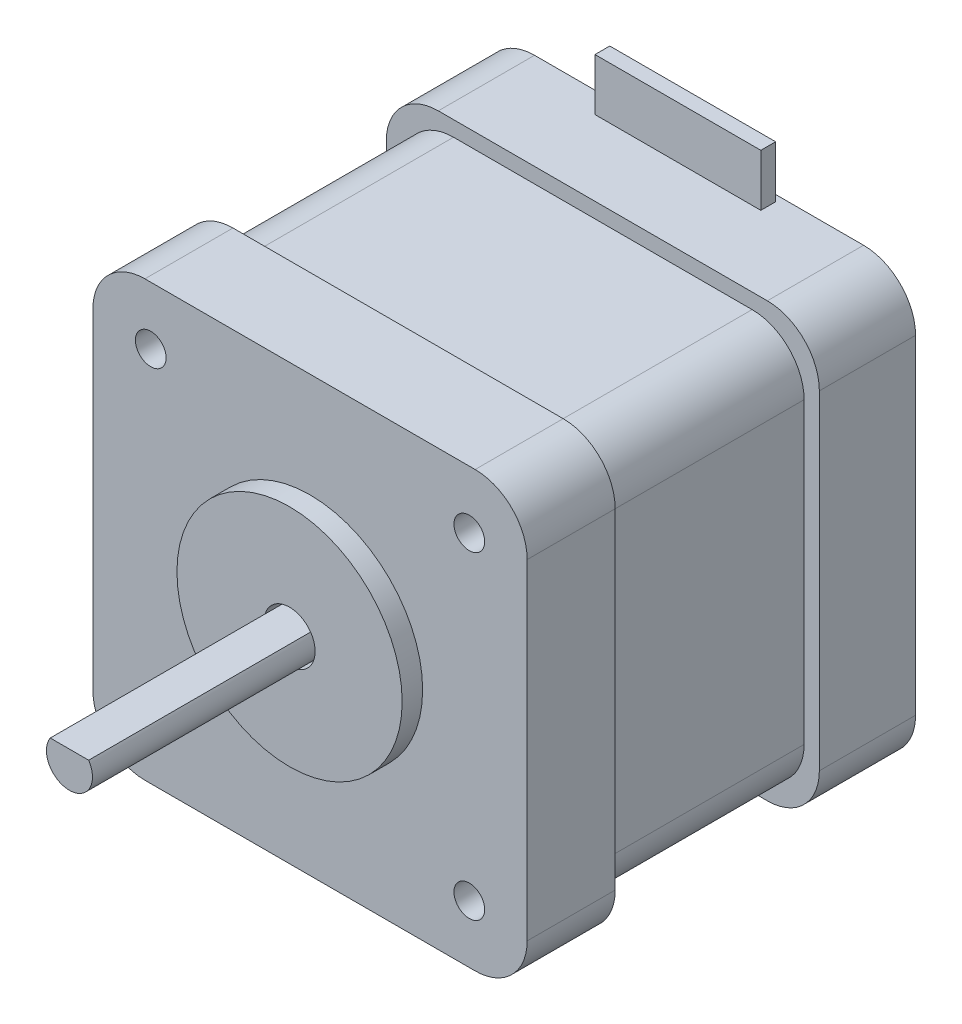
from build123d import *

# Parameters (mm, degrees)
BOSS_EXTRUDE1_DEPTH = 9.4
BOSS_EXTRUDE2_DEPTH = 20
BOSS_EXTRUDE4_DEPTH = 8.6
SKETCH5_R           = 11
BOSS_EXTRUDE5_DEPTH = 2
SKETCH6_R           = 2.5
CUT_EXTRUDE1_DEPTH  = 2
BOSS_EXTRUDE6_DEPTH = 23.5
SKETCH8_W           = 16.2
SKETCH8_H           = 1.444611315
BOSS_EXTRUDE7_DEPTH = 5.08
SKETCH9_R           = 1.5
CUT_EXTRUDE2_DEPTH  = 4.5


with BuildPart() as part:
    # Sketch1 → Boss-Extrude1 (new body)
    with BuildSketch(Plane.XY):
        with BuildLine():
            Line((-16.07, -21.15), (16.07, -21.15))
            ThreePointArc((16.07, -21.15), (19.662102448, -19.662102448), (21.15, -16.07))
            Line((21.15, -16.07), (21.15, 16.07))
            ThreePointArc((21.15, 16.07), (19.662102448, 19.662102448), (16.07, 21.15))
            Line((16.07, 21.15), (-16.07, 21.15))
            ThreePointArc((-16.07, 21.15), (-19.662102448, 19.662102448), (-21.15, 16.07))
            Line((-21.15, 16.07), (-21.15, -16.07))
            ThreePointArc((-21.15, -16.07), (-19.662102448, -19.662102448), (-16.07, -21.15))
        make_face()
    extrude(amount=BOSS_EXTRUDE1_DEPTH)

    # Sketch2 → Boss-Extrude2 (add)
    with BuildSketch(Plane.XY.offset(9.4)):
        with BuildLine():
            Line((-14.582102448, -19.662102448), (14.582102448, -19.662102448))
            ThreePointArc((14.582102448, -19.662102448), (18.174204897, -18.174204897), (19.662102448, -14.582102448))
            Line((19.662102448, -14.582102448), (19.662102448, 14.582102448))
            ThreePointArc((19.662102448, 14.582102448), (18.174204897, 18.174204897), (14.582102448, 19.662102448))
            Line((14.582102448, 19.662102448), (-14.582102448, 19.662102448))
            ThreePointArc((-14.582102448, 19.662102448), (-18.174204897, 18.174204897), (-19.662102448, 14.582102448))
            Line((-19.662102448, 14.582102448), (-19.662102448, -14.582102448))
            ThreePointArc((-19.662102448, -14.582102448), (-18.174204897, -18.174204897), (-14.582102448, -19.662102448))
        make_face()
    extrude(amount=BOSS_EXTRUDE2_DEPTH)

    # Sketch4 → Boss-Extrude4 (add)
    with BuildSketch(Plane.XY.offset(29.4)):
        with BuildLine():
            Line((16.129, -21.209), (-16.129, -21.209))
            ThreePointArc((-16.129, -21.209), (-19.721102448, -19.721102448), (-21.209, -16.129))
            Line((-21.209, -16.129), (-21.209, 16.129))
            ThreePointArc((-21.209, 16.129), (-19.721102448, 19.721102448), (-16.129, 21.209))
            Line((-16.129, 21.209), (16.129, 21.209))
            ThreePointArc((16.129, 21.209), (19.721102448, 19.721102448), (21.209, 16.129))
            Line((21.209, 16.129), (21.209, -16.129))
            ThreePointArc((21.209, -16.129), (19.721102448, -19.721102448), (16.129, -21.209))
        make_face()
    extrude(amount=BOSS_EXTRUDE4_DEPTH)

    # Sketch5 → Boss-Extrude5 (add)
    with BuildSketch(Plane.XY.offset(38)):
        Circle(SKETCH5_R)
    extrude(amount=BOSS_EXTRUDE5_DEPTH)

    # Sketch6 → Cut-Extrude1 (cut)
    with BuildSketch(Plane.XY.offset(40)):
        Circle(SKETCH6_R)
    extrude(amount=-CUT_EXTRUDE1_DEPTH, mode=Mode.SUBTRACT)

    # Sketch7 → Boss-Extrude6 (add)
    with BuildSketch(Plane.XY.offset(38)):
        with BuildLine():
            Line((1.876071115, 1.242118018), (-1.876071115, 1.242118018))
            ThreePointArc((-1.876071115, 1.242118018), (0, -2.25), (1.876071115, 1.242118018))
        make_face()
    extrude(amount=BOSS_EXTRUDE6_DEPTH)

    # Sketch8 → Boss-Extrude7 (add)
    with BuildSketch(Plane(origin=(0, 21.15, 0), x_dir=(1, 0, 0), z_dir=(0, 1, 0))):
        with Locations((0, -1.343147685)):
            Rectangle(SKETCH8_W, SKETCH8_H)
    extrude(amount=BOSS_EXTRUDE7_DEPTH)

    # Sketch9 → Cut-Extrude2 (cut)
    with BuildSketch(Plane.XY.offset(38)):
        with Locations((-15.559, 15.559)):
            Circle(SKETCH9_R)
        with Locations((15.559, 15.559)):
            Circle(SKETCH9_R)
        with Locations((15.559, -15.559)):
            Circle(SKETCH9_R)
        with Locations((-15.559, -15.559)):
            Circle(SKETCH9_R)
    extrude(amount=-CUT_EXTRUDE2_DEPTH, mode=Mode.SUBTRACT)


solid = part.part
